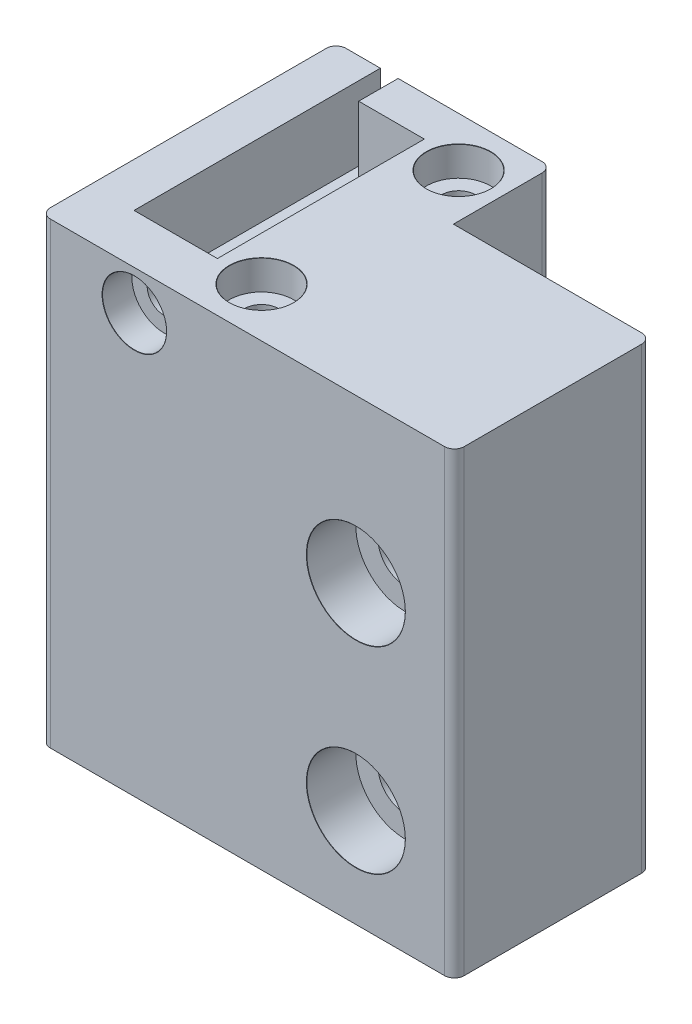
from build123d import *

# Parameters (mm, degrees)
SKETCH1_W                     = 42
SKETCH1_H                     = 20
BOSS_EXTRUDE1_DEPTH           = 40
CBORE_FOR_M5_SHCS1_AT_2_COUNT = 2
CBORE_FOR_M5_SHCS1_AT_2_PITCH = 20
SKETCH5_W                     = 42
SKETCH5_H                     = 20
BOSS_EXTRUDE2_DEPTH           = 6.5
SKETCH12_W                    = 21.9
SKETCH12_H                    = 10
BOSS_EXTRUDE3_DEPTH           = 46.5
CUT_EXTRUDE1_DEPTH            = 7.5
FILLET1_R                     = 1
CBORE_FOR_M3_SHCS2_AT_2_COUNT = 2
CBORE_FOR_M3_SHCS2_AT_2_PITCH = 20
CUT_EXTRUDE2_DEPTH            = 8


with BuildPart() as part:
    # Sketch1 → Boss-Extrude1 (new body)
    with BuildSketch(Plane(origin=(0, 0, 0), x_dir=(1, 0, 0), z_dir=(0, 1, 0))):
        Rectangle(SKETCH1_W, SKETCH1_H)
    extrude(amount=BOSS_EXTRUDE1_DEPTH)

    # Sketch4 → CBORE for M5 SHCS1 (revolve, cut)
    with BuildSketch(Plane(origin=(11, 30, 10), x_dir=(0, -1, 0), z_dir=(1, 0, 0))):
        Polygon((0, 0), (0, 20), (2.75, 20), (2.75, 5), (5, 5), (5, 0.020977491), (5.025, 0), align=None)
    cbore_for_m5_shcs1 = revolve(axis=Axis((11, 30, 16.35), (0, 0, -1)), mode=Mode.SUBTRACT)

    # CBORE for M5 SHCS1 at 2: CBORE for M5 SHCS1 ×2
    with Locations(*[(0, -i * CBORE_FOR_M5_SHCS1_AT_2_PITCH, 0) for i in range(1, CBORE_FOR_M5_SHCS1_AT_2_COUNT)]):
        add(cbore_for_m5_shcs1, mode=Mode.SUBTRACT)

    # Sketch5 → Boss-Extrude2 (add)
    with BuildSketch(Plane(origin=(0, 40, 0), x_dir=(1, 0, 0), z_dir=(0, 1, 0))):
        Rectangle(SKETCH5_W, SKETCH5_H)
    extrude(amount=BOSS_EXTRUDE2_DEPTH)

    # Sketch12 → Boss-Extrude3 (add)
    with BuildSketch(Plane(origin=(0, 46.5, 0), x_dir=(1, 0, 0), z_dir=(0, 1, 0))):
        with Locations((-10.05, 15)):
            Rectangle(SKETCH12_W, SKETCH12_H)
    extrude(amount=-BOSS_EXTRUDE3_DEPTH)

    # Sketch6 → Cut-Extrude1 (cut)
    with BuildSketch(Plane(origin=(0, 46.5, 0), x_dir=(1, 0, 0), z_dir=(0, 1, 0))):
        Polygon((-16.51, 20), (-16.51, -5), (-8.05, -5), (-8.05, 16), (-14.71, 16), (-14.71, 20), align=None)
    extrude(amount=-CUT_EXTRUDE1_DEPTH, mode=Mode.SUBTRACT)

    # Fillet1
    fillet1_edges = [part.edges().sort_by_distance(p)[0] for p in [
        (0.9, 23.25, -20),
        (-21, 23.25, -20),
        (21, 23.25, -10),
        (21, 23.25, 10),
        (-21, 23.25, 10),
    ]]
    fillet(fillet1_edges, radius=FILLET1_R)

    # Sketch11 → CBORE for M3 SHCS1 (revolve, cut)
    with BuildSketch(Plane(origin=(-11.48, 42.5, 10), x_dir=(0, -1, 0), z_dir=(1, 0, 0))):
        Polygon((0, 0), (0, 6.021463052), (1.7, 5), (1.7, 3), (3.25, 3), (3.25, 0.020977491), (3.275, 0), align=None)
    revolve(axis=Axis((-11.48, 42.5, 16.35), (0, 0, -1)), mode=Mode.SUBTRACT)

    # Sketch16 → CBORE for M3 SHCS2 (revolve, cut)
    with BuildSketch(Plane(origin=(-3.575, 46.5, -15), x_dir=(0, 0, 1), z_dir=(1, 0, 0))):
        Polygon((0, 0), (0, 46.5), (1.7, 46.5), (1.7, 3), (3.25, 3), (3.25, 0.020977491), (3.275, 0), align=None)
    cbore_for_m3_shcs2 = revolve(axis=Axis((-3.575, 52.85, -15), (0, -1, 0)), mode=Mode.SUBTRACT)

    # CBORE for M3 SHCS2 at 2: CBORE for M3 SHCS2 ×2
    with Locations(*[(0, 0, i * CBORE_FOR_M3_SHCS2_AT_2_PITCH) for i in range(1, CBORE_FOR_M3_SHCS2_AT_2_COUNT)]):
        add(cbore_for_m3_shcs2, mode=Mode.SUBTRACT)

    # Sketch18 → Cut-Extrude2 (cut)
    with BuildSketch(Plane.XZ):
        Polygon((-0.475, 5), (-2.025, 7.684678752), (-5.125, 7.684678752), (-6.675, 5), (-5.125, 2.315321248), (-2.025, 2.315321248), align=None)
        Polygon((-0.475, -15), (-2.025, -12.315321248), (-5.125, -12.315321248), (-6.675, -15), (-5.125, -17.684678752), (-2.025, -17.684678752), align=None)
    extrude(amount=-CUT_EXTRUDE2_DEPTH, mode=Mode.SUBTRACT)


solid = part.part
